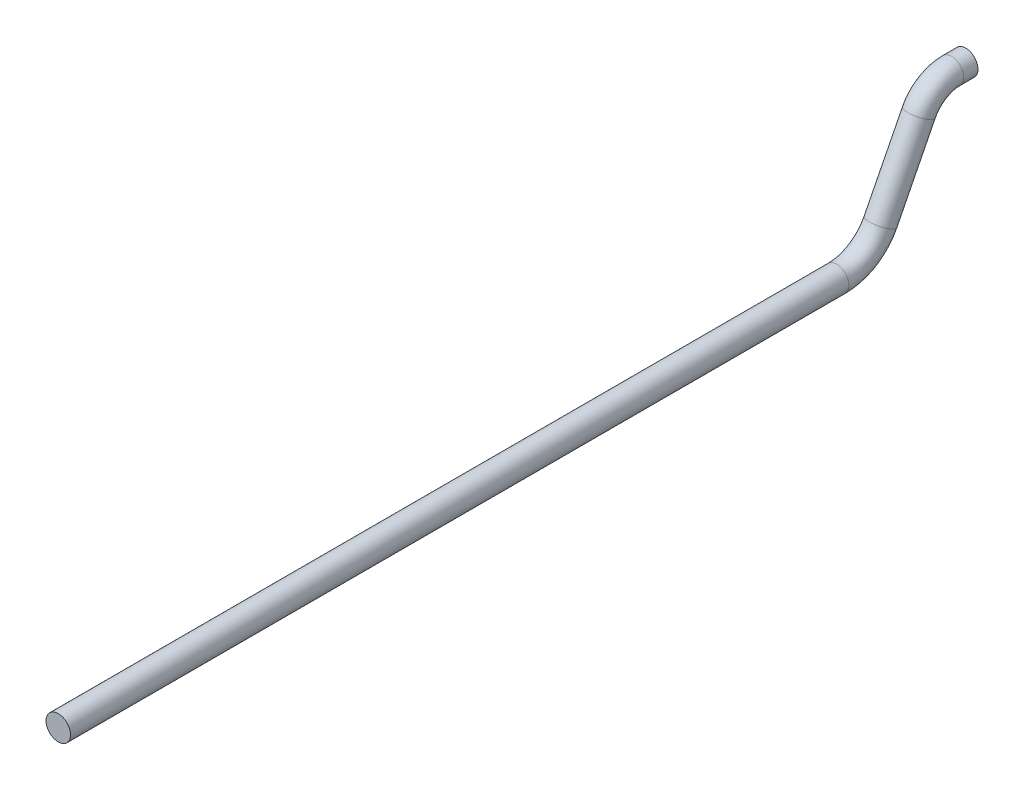
from build123d import *

# Parameters (mm, degrees)
SWEEP1_PROFILE_R = 5


with BuildPart() as part:
    # Sweep1: sweep along a path in Sketch1
    with BuildLine(Plane(origin=(0, 0, 0), x_dir=(0, 0, -1), z_dir=(1, 0, 0))) as sweep1_path:
        Line((0, 0), (-5.784603478, 0))
        ThreePointArc((-5.784603478, 0), (-13.636562217, -2.219282338), (-19.16509251, -8.22043414))
        Line((-19.16509251, -8.22043414), (-34.780317907, -39.039421147))
        ThreePointArc((-34.780317907, -39.039421147), (-42.15169163, -47.040956882), (-52.62096995, -50))
        Line((-52.62096995, -50), (-370, -50))
    # Sweep1 profile (on start of the path) → Sweep1 (sweep)
    with BuildSketch(Plane(origin=(0, 0, 0), x_dir=(0, 1, 0), z_dir=(0, 0, 1))):
        Circle(SWEEP1_PROFILE_R)
    sweep(path=sweep1_path.line)


solid = part.part
